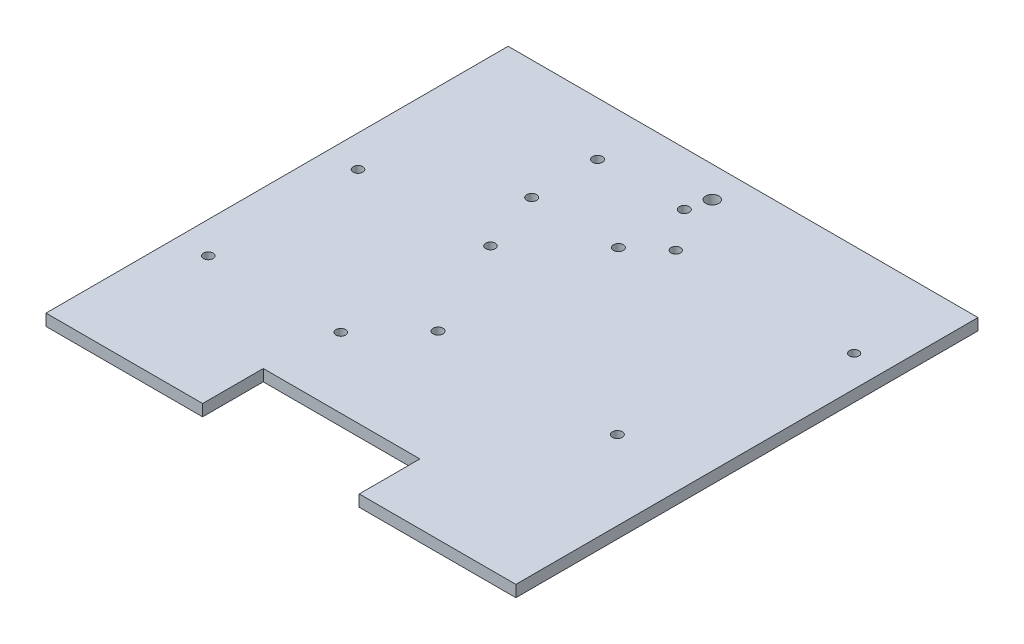
from build123d import *

# Parameters (mm, degrees)
SKETCH1_W           = 193.68
SKETCH1_H           = 190.5
BOSS_EXTRUDE1_DEPTH = 4.78
SKETCH2_R           = 2.6797
CUT_EXTRUDE1_DEPTH  = 5.78
CUT_EXTRUDE2_DEPTH  = 5.78
SKETCH4_R           = 1.936199963
SKETCH4_R_2         = 2.048699992
SKETCH4_R_3         = 1.9812
SKETCH4_R_4         = 2.038700012
CUT_EXTRUDE3_DEPTH  = 5.78


with BuildPart() as part:
    # Sketch1 → Boss-Extrude1 (new body)
    with BuildSketch(Plane(origin=(0, 0, 0), x_dir=(1, 0, 0), z_dir=(0, 1, 0))):
        Rectangle(SKETCH1_W, SKETCH1_H)
    extrude(amount=BOSS_EXTRUDE1_DEPTH)

    # Sketch2 → Cut-Extrude1 (cut, through all)
    with BuildSketch(Plane(origin=(0, 4.78, 0), x_dir=(1, 0, 0), z_dir=(0, 1, 0))):
        with Locations((0, 82.55)):
            Circle(SKETCH2_R)
    extrude(amount=-CUT_EXTRUDE1_DEPTH, mode=Mode.SUBTRACT)

    # Sketch3 → Cut-Extrude2 (cut, through all)
    with BuildSketch(Plane(origin=(0, 4.78, 0), x_dir=(1, 0, 0), z_dir=(0, 1, 0))):
        Polygon((0, -95.25), (-32.28, -95.25), (-32.28, -70.249999962), (32.28, -70.249999962), (32.28, -95.25), align=None)
    extrude(amount=-CUT_EXTRUDE2_DEPTH, mode=Mode.SUBTRACT)

    # Sketch4 → Cut-Extrude3 (cut, through all)
    with BuildSketch(Plane(origin=(0, 4.78, 0), x_dir=(1, 0, 0), z_dir=(0, 1, 0))):
        with Locations((10.5225, 56.962500062)):
            Circle(SKETCH4_R)
        with Locations((84.0775, 56.9625)):
            Circle(SKETCH4_R)
        with Locations((-38.005, 73.274999999)):
            Circle(SKETCH4_R_2)
        with Locations((-2.255, 73.275)):
            Circle(SKETCH4_R_2)
        with Locations((-2.255, 46.125)):
            Circle(SKETCH4_R_2)
        with Locations((-38.005, 46.125000001)):
            Circle(SKETCH4_R_2)
        with Locations((-83.8225, -41.381999999)):
            Circle(SKETCH4_R_3)
        with Locations((-83.822499999, 20.340000001)):
            Circle(SKETCH4_R_3)
        with Locations((-29.212499999, 20.34)):
            Circle(SKETCH4_R_3)
        with Locations((-29.2125, -41.382)):
            Circle(SKETCH4_R_3)
        with Locations((64.27, -20.864999962)):
            Circle(SKETCH4_R_4)
        with Locations((-9.61, -20.864999962)):
            Circle(SKETCH4_R_4)
    extrude(amount=-CUT_EXTRUDE3_DEPTH, mode=Mode.SUBTRACT)


solid = part.part
